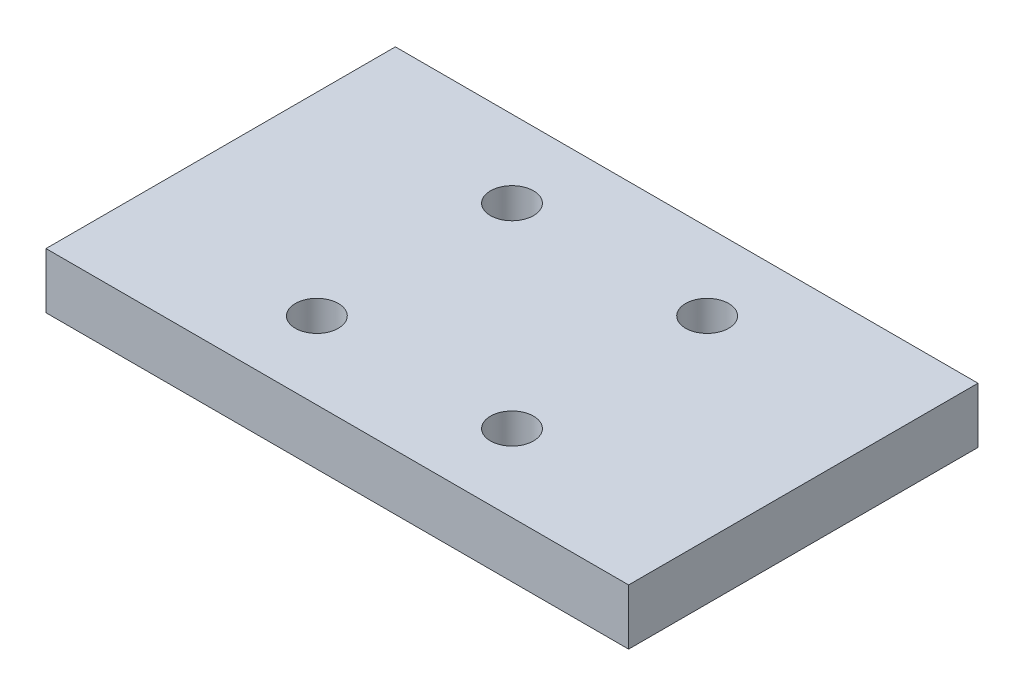
from build123d import *

# Parameters (mm, degrees)
SKETCH1_W                              = 66.500577654
SKETCH1_H                              = 39.878
BOSS_EXTRUDE1_DEPTH                    = 6.35
F_10_0_1935_DIAMETER_HOLE1_D           = 4.9149
F_10_0_1935_DIAMETER_HOLE1_CSINK_D     = 6.1849
F_10_0_1935_DIAMETER_HOLE1_CSINK_ANGLE = 90


with BuildPart() as part:
    # Sketch1 → Boss-Extrude1 (new body)
    with BuildSketch(Plane(origin=(0, 0, 0), x_dir=(1, 0, 0), z_dir=(0, 1, 0))):
        Rectangle(SKETCH1_W, SKETCH1_H)
    extrude(amount=BOSS_EXTRUDE1_DEPTH)

    # #10 (0.1935) Diameter Hole1 (through all)
    with Locations(Plane(origin=(0, 0, 0), x_dir=(-1, 0, 0), z_dir=(0, -1, 0))):
        with Locations((-11.136931804, 11.136931804), (11.136931804, 11.136931804), (11.136931804, -11.136931804), (-11.136931804, -11.136931804)):
            CounterSinkHole(F_10_0_1935_DIAMETER_HOLE1_D / 2, F_10_0_1935_DIAMETER_HOLE1_CSINK_D / 2, counter_sink_angle=F_10_0_1935_DIAMETER_HOLE1_CSINK_ANGLE)


solid = part.part
